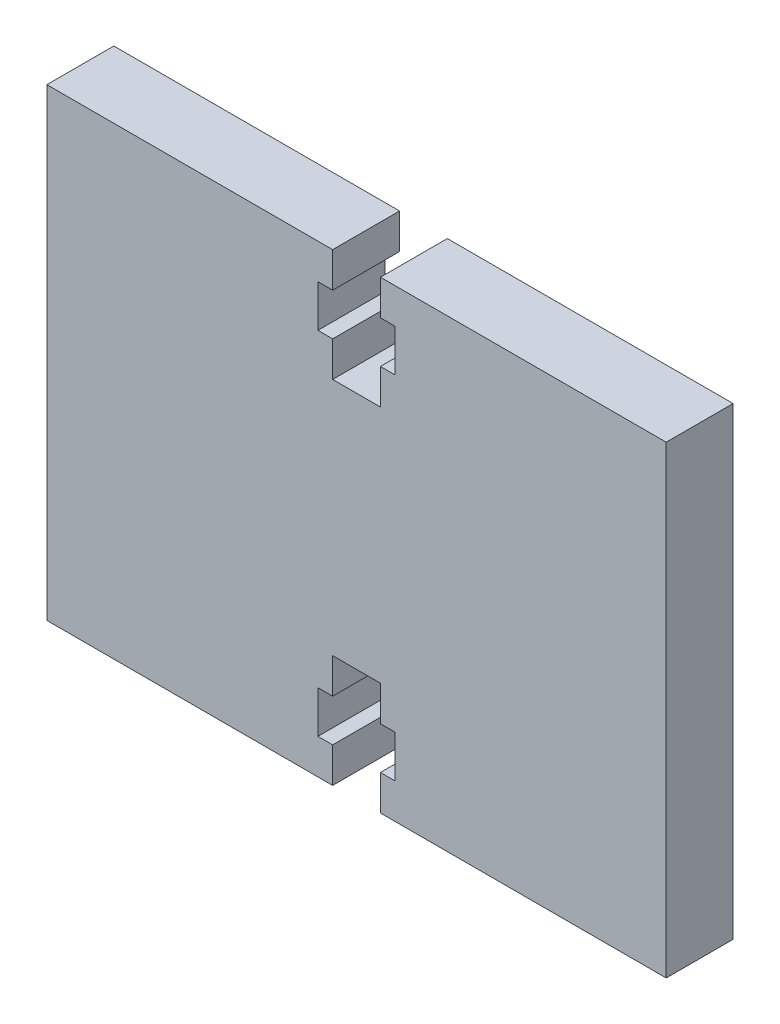
from build123d import *

# Parameters (mm, degrees)
BOSS_EXTRUDE1_DEPTH = 4.7625


with BuildPart() as part:
    # Sketch1 → Boss-Extrude1 (new body)
    with BuildSketch(Plane.XY):
        Polygon((-22.0345, -16.51), (-1.7, -16.51), (-1.7, -14.01), (-2.75, -14.01), (-2.75, -11.01), (-1.7, -11.01), (-1.7, -8.51), (1.7, -8.51), (1.7, -11.01), (2.75, -11.01), (2.75, -14.01), (1.7, -14.01), (1.7, -16.51), (22.0345, -16.51), (22.0345, 16.51), (1.7, 16.51), (1.7, 14.01), (2.75, 14.01), (2.75, 11.01), (1.7, 11.01), (1.7, 8.51), (-1.7, 8.51), (-1.7, 11.01), (-2.75, 11.01), (-2.75, 14.01), (-1.7, 14.01), (-1.7, 16.51), (-22.0345, 16.51), align=None)
    extrude(amount=BOSS_EXTRUDE1_DEPTH)


solid = part.part
